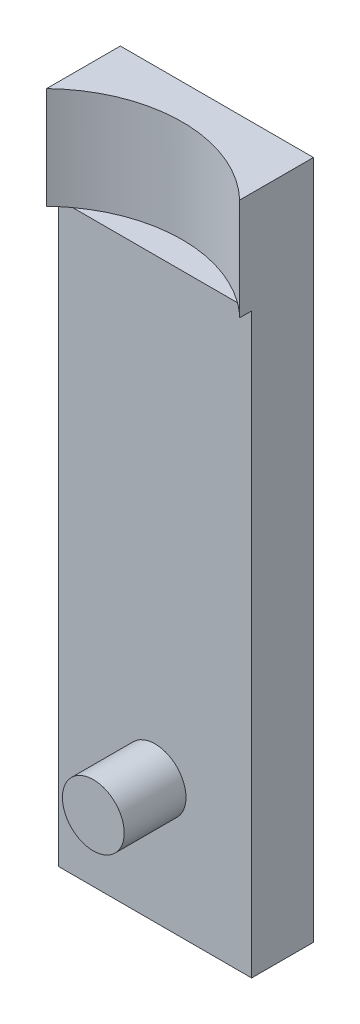
from build123d import *

# Parameters (mm, degrees)
SKETCH1_W           = 62.5
SKETCH1_H           = 220
BOSS_EXTRUDE1_DEPTH = 20
SKETCH2_W           = 62.5
SKETCH2_H           = 33
BOSS_EXTRUDE2_DEPTH = 5
SKETCH3_R           = 10
CUT_EXTRUDE1_DEPTH  = 21
CUT_EXTRUDE2_DEPTH  = 33
SKETCH5_R           = 10
BOSS_EXTRUDE3_DEPTH = 20
SKETCH6_W           = 3.761588262
SKETCH6_H           = 3.524392854
CUT_EXTRUDE3_DEPTH  = 7


with BuildPart() as part:
    # Sketch1 → Boss-Extrude1 (new body)
    with BuildSketch(Plane.XY):
        Rectangle(SKETCH1_W, SKETCH1_H)
    extrude(amount=BOSS_EXTRUDE1_DEPTH)

    # Sketch2 → Boss-Extrude2 (add)
    with BuildSketch(Plane.XY.offset(20)):
        with Locations((0, 93.5)):
            Rectangle(SKETCH2_W, SKETCH2_H)
    extrude(amount=BOSS_EXTRUDE2_DEPTH)

    # Sketch3 → Cut-Extrude1 (cut, through all)
    with BuildSketch(Plane.XY.offset(20)):
        with Locations((0, -70)):
            Circle(SKETCH3_R)
    extrude(amount=-CUT_EXTRUDE1_DEPTH, mode=Mode.SUBTRACT)

    # Sketch4 → Cut-Extrude2 (cut)
    with BuildSketch(Plane(origin=(0, 110, 0), x_dir=(1, 0, 0), z_dir=(0, 1, 0))):
        with BuildLine():
            Line((30.073382628, -25), (31.25, -25))
            Line((31.25, -25), (31.25, -23.870415383))
            ThreePointArc((31.25, -23.870415383), (0, -11.25), (-31.25, -23.870415383))
            Line((-31.25, -23.870415383), (-31.25, -25))
            Line((-31.25, -25), (30.073382628, -25))
        make_face()
    extrude(amount=-CUT_EXTRUDE2_DEPTH, mode=Mode.SUBTRACT)

    # Sketch6 → Cut-Extrude3 (cut)
    with BuildSketch(Plane(origin=(0, 0, 0), x_dir=(-1, 0, 0), z_dir=(0, 0, -1))):
        with Locations((-11.460210717, -71.107433841)):
            Rectangle(SKETCH6_W, SKETCH6_H)
    extrude(amount=-CUT_EXTRUDE3_DEPTH, mode=Mode.SUBTRACT)


with BuildPart() as body_2:
    # Sketch5 → Boss-Extrude3 (new body)
    with BuildSketch(Plane.XY.offset(20)):
        with Locations((0, -70)):
            Circle(SKETCH5_R)
    extrude(amount=BOSS_EXTRUDE3_DEPTH)


solid = Compound([part.part, body_2.part])
